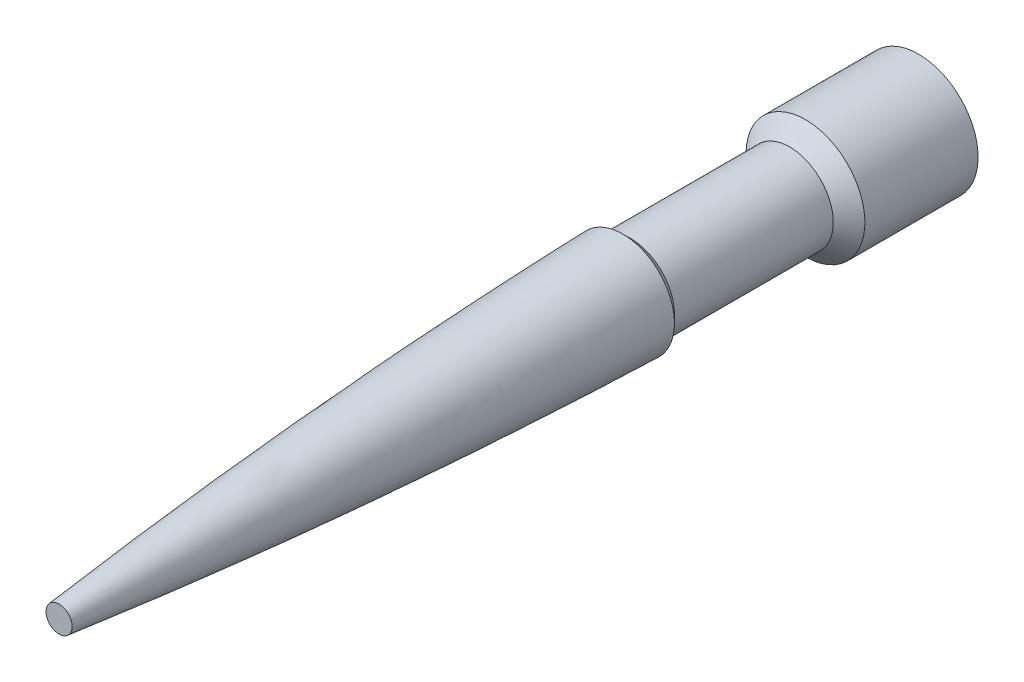
from build123d import *


with BuildPart() as part:
    # Sketch1 → Revolve1 (revolve)
    with BuildSketch(Plane(origin=(0, 0, 0), x_dir=(1, 0, 0), z_dir=(0, 1, 0))):
        with BuildLine():
            Line((0, 0), (0, -108.493072777))
            Line((0, -108.493072777), (1.647963045, -108.493072777))
            add(Edge.make_bspline(
                [(6.504116771, -37.330573794), (5.545242456, -73.016533956), (1.647963045, -108.493072777)],
                knots=[0, 0, 0, 1, 1, 1], degree=2))
            Line((6.504116771, -37.330573794), (5.508233542, -36.334690565))
            Line((5.508233542, -36.334690565), (5.508233542, -16.28474128))
            Line((5.508233542, -16.28474128), (7.5, -14.292974822))
            Line((7.5, -14.292974822), (7.5, 0))
            Line((7.5, 0), (0, 0))
        make_face()
    revolve(axis=Axis((0, 0, 0), (0, 0, 1)))


solid = part.part
